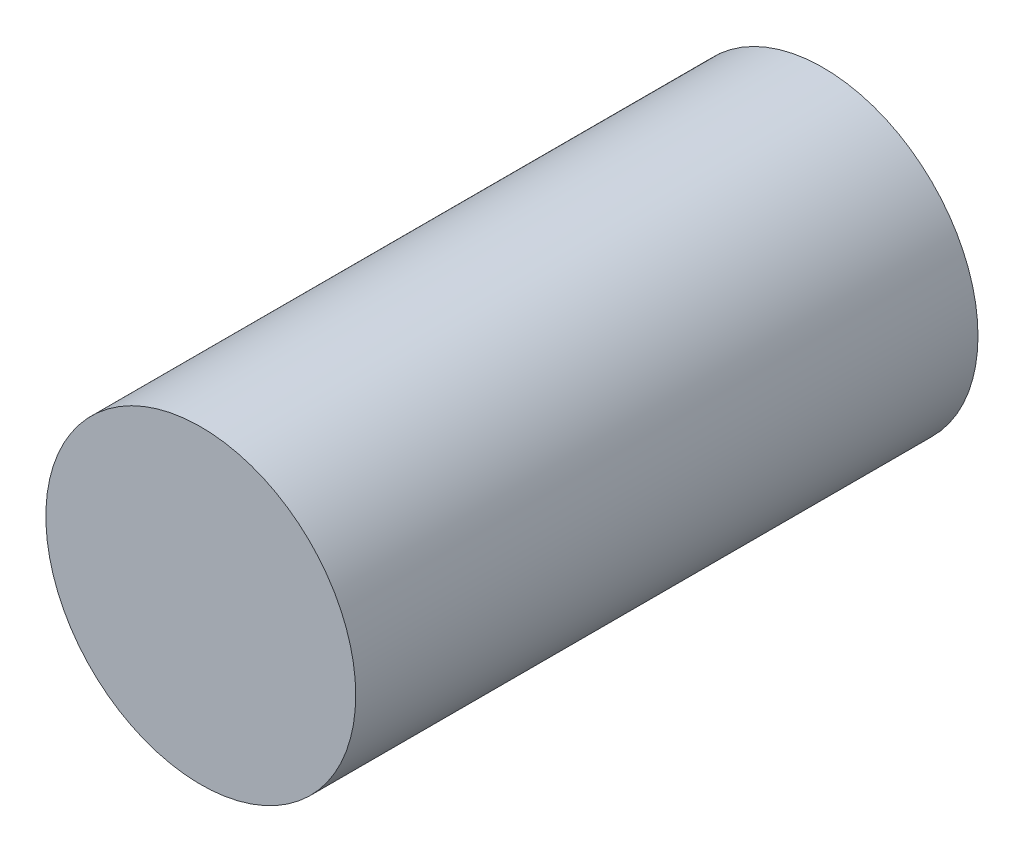
from build123d import *

# Parameters (mm, degrees)
SKETCH1_R           = 2.49
BOSS_EXTRUDE1_DEPTH = 10


with BuildPart() as part:
    # Sketch1 → Boss-Extrude1 (new body)
    with BuildSketch(Plane.XY):
        Circle(SKETCH1_R)
    extrude(amount=BOSS_EXTRUDE1_DEPTH)


solid = part.part
